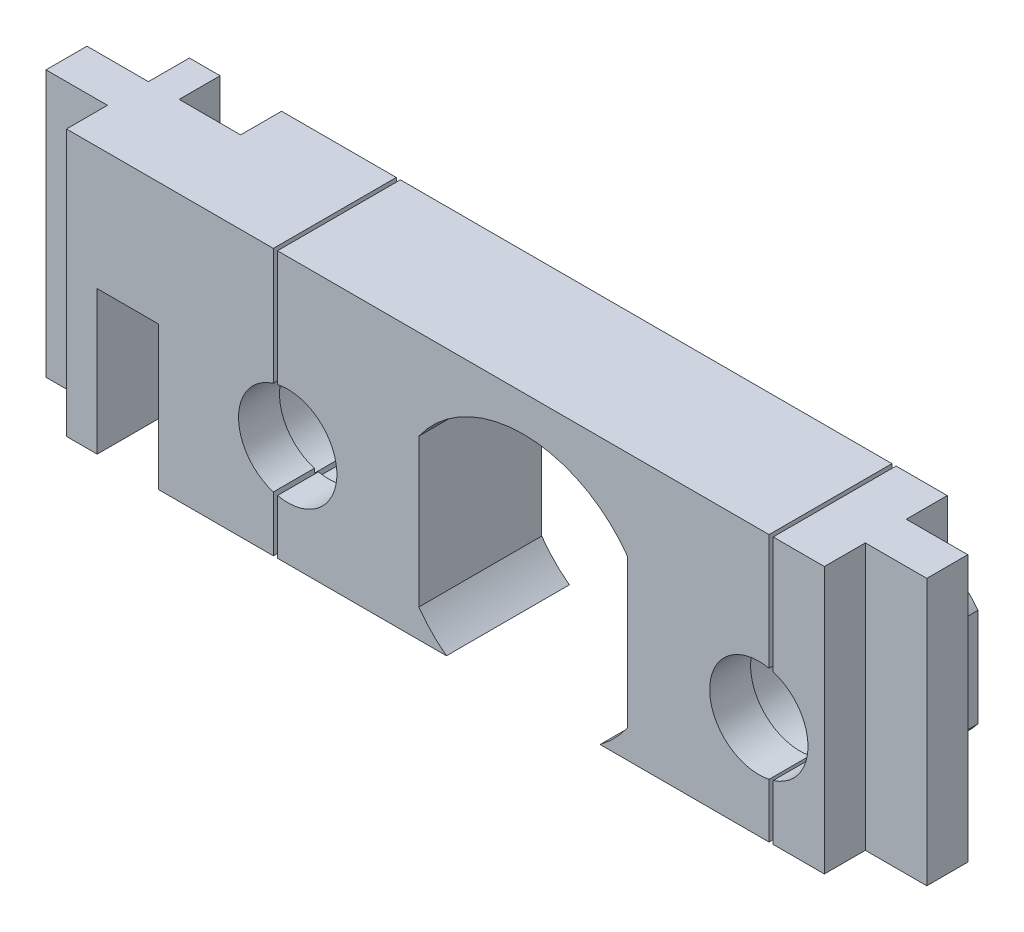
from build123d import *

# Parameters (mm, degrees)
SKETCH1_R            = 1
BOSS_EXTRUDE1_DEPTH  = 6
SKETCH2_R            = 2.6
CUT_EXTRUDE1_DEPTH   = 6
SKETCH3_W            = 7.6
SKETCH3_H            = 13
BOSS_EXTRUDE2_DEPTH  = 6
BOSS_EXTRUDE5_START  = -5
SKETCH6_W            = 3
SKETCH6_H            = 2
BOSS_EXTRUDE5_DEPTH  = 13
BOSS_EXTRUDE6_START  = -6
SKETCH10_R           = 4
SKETCH10_R_2         = 2.6
BOSS_EXTRUDE6_DEPTH  = 1.5
BOSS_EXTRUDE7_START  = -6
SKETCH12_R           = 2.6
SKETCH12_R_2         = 2.4
BOSS_EXTRUDE7_DEPTH  = 2
CUT_EXTRUDE2_DEPTH   = 7
SKETCH14_W           = 3
SKETCH14_H           = 6
CUT_EXTRUDE3_DEPTH   = 2
SKETCH15_W           = 0.2
SKETCH15_H           = 13
CUT_EXTRUDE5_DEPTH   = 7.5
SKETCH16_W           = 3
SKETCH16_H           = 3
CUT_EXTRUDE6_DEPTH   = 3
SKETCH17_W           = 2.8
SKETCH17_H           = 2.8
BOSS_EXTRUDE9_DEPTH  = 3
BOSS_EXTRUDE10_START = 24.4
SKETCH17_2_W         = 2.8
SKETCH17_2_H         = 2.8
BOSS_EXTRUDE10_DEPTH = 3


with BuildPart() as part:
    # Sketch1 → Boss-Extrude1 (new body)
    with BuildSketch(Plane.XY):
        with BuildLine():
            ThreePointArc((3.75, -5), (4.47902769, -4.358991965), (5.1, -3.61282438))
            Line((5.1, -3.61282438), (5.1, 3.61282438))
            ThreePointArc((5.1, 3.61282438), (0, 6.25), (-5.1, 3.61282438))
            Line((-5.1, 3.61282438), (-5.1, -3.61282438))
            ThreePointArc((-5.1, -3.61282438), (-4.47902769, -4.358991965), (-3.75, -5))
            Line((-3.75, -5), (-14.7, -5))
            Line((-14.7, -5), (-14.7, 8))
            Line((-14.7, 8), (14.7, 8))
            Line((14.7, 8), (14.7, -5))
            Line((14.7, -5), (3.75, -5))
        make_face()
        with Locations((11.5, 0)):
            Circle(SKETCH1_R, mode=Mode.SUBTRACT)
        with Locations((-11.5, 0)):
            Circle(SKETCH1_R, mode=Mode.SUBTRACT)
    extrude(amount=BOSS_EXTRUDE1_DEPTH)

    # Sketch2 → Cut-Extrude1 (cut)
    with BuildSketch(Plane.XY):
        with Locations((-11.5, 0)):
            Circle(SKETCH2_R)
        with Locations((11.5, 0)):
            Circle(SKETCH2_R)
    extrude(amount=CUT_EXTRUDE1_DEPTH, mode=Mode.SUBTRACT)

    # Sketch3 → Boss-Extrude2 (add)
    with BuildSketch(Plane.XY):
        with Locations((-18.5, 1.5)):
            Rectangle(SKETCH3_W, SKETCH3_H)
    extrude(amount=BOSS_EXTRUDE2_DEPTH)

    # Sketch6 → Boss-Extrude5 (add)
    with BuildSketch(Plane(origin=(0, 0, 0), x_dir=(1, 0, 0), z_dir=(0, 1, 0)).offset(BOSS_EXTRUDE5_START)):
        with Locations((-23.8, -3)):
            Rectangle(SKETCH6_W, SKETCH6_H)
        with Locations((16.2, -3)):
            Rectangle(SKETCH6_W, SKETCH6_H)
    extrude(amount=BOSS_EXTRUDE5_DEPTH)

    # Sketch10 → Boss-Extrude6 (add)
    with BuildSketch(Plane.XY.offset(6).offset(BOSS_EXTRUDE6_START)):
        with Locations((-11.5, 0)):
            Circle(SKETCH10_R)
        with Locations((-11.5, 0)):
            Circle(SKETCH10_R_2, mode=Mode.SUBTRACT)
        with BuildLine():
            Line((14.7, 2.4), (14.7, -2.4))
            ThreePointArc((14.7, -2.4), (7.5, 0), (14.7, 2.4))
        make_face()
        with Locations((11.5, 0)):
            Circle(SKETCH10_R_2, mode=Mode.SUBTRACT)
    extrude(amount=-BOSS_EXTRUDE6_DEPTH)

    # Sketch12 → Boss-Extrude7 (add)
    with BuildSketch(Plane(origin=(0, 0, 0), x_dir=(-1, 0, 0), z_dir=(0, 0, -1)).offset(BOSS_EXTRUDE7_START)):
        with Locations((11.5, 0)):
            Circle(SKETCH12_R)
        with Locations((11.5, 0)):
            Circle(SKETCH12_R_2, mode=Mode.SUBTRACT)
        with Locations((-11.5, 0)):
            Circle(SKETCH12_R)
        with Locations((-11.5, 0)):
            Circle(SKETCH12_R_2, mode=Mode.SUBTRACT)
    extrude(amount=BOSS_EXTRUDE7_DEPTH)

    # Sketch13 → Cut-Extrude2 (cut)
    with BuildSketch(Plane.XZ.offset(5)):
        Polygon((-22.3, 0), (-16.3, 0), (-16.3, 2), (-17.8, 2), (-17.8, 6), (-20.8, 6), (-20.8, 2), (-22.3, 2), align=None)
    extrude(amount=-CUT_EXTRUDE2_DEPTH, mode=Mode.SUBTRACT)

    # Sketch14 → Cut-Extrude3 (cut)
    with BuildSketch(Plane(origin=(0, 0, 0), x_dir=(-1, 0, 0), z_dir=(0, 0, -1))):
        with Locations((19.3, 5)):
            Rectangle(SKETCH14_W, SKETCH14_H)
    extrude(amount=-CUT_EXTRUDE3_DEPTH, mode=Mode.SUBTRACT)

    # Sketch15 → Cut-Extrude5 (cut, symmetric)
    with BuildSketch(Plane.XY):
        with Locations((-12.1, 1.5)):
            Rectangle(SKETCH15_W, SKETCH15_H)
        with Locations((12.1, 1.5)):
            Rectangle(SKETCH15_W, SKETCH15_H)
    extrude(amount=CUT_EXTRUDE5_DEPTH, both=True, mode=Mode.SUBTRACT)

    # Sketch16 → Cut-Extrude6 (cut)
    with BuildSketch(Plane(origin=(12, 0, 0), x_dir=(0, 0, -1), z_dir=(1, 0, 0))):
        with Locations((-3, 5.173669459)):
            Rectangle(SKETCH16_W, SKETCH16_H)
    cut_extrude6 = extrude(amount=-CUT_EXTRUDE6_DEPTH, mode=Mode.SUBTRACT)

    # Mirror1: Cut-Extrude6 across plane
    add(cut_extrude6.mirror(Plane(origin=(0, 0, 0), x_dir=(0, 0, 1), z_dir=(1, 0, 0))), mode=Mode.SUBTRACT)

    # Sketch17 → Boss-Extrude9 (add)
    with BuildSketch(Plane(origin=(-12.2, 0, 0), x_dir=(0, 0, -1), z_dir=(1, 0, 0))):
        with Locations((-3, 5.173669459)):
            Rectangle(SKETCH17_W, SKETCH17_H)
    extrude(amount=BOSS_EXTRUDE9_DEPTH)

    # Sketch17_2 → Boss-Extrude10 (add)
    with BuildSketch(Plane(origin=(-12.2, 0, 0), x_dir=(0, 0, -1), z_dir=(1, 0, 0)).offset(BOSS_EXTRUDE10_START)):
        with Locations((-3, 5.173669459)):
            Rectangle(SKETCH17_2_W, SKETCH17_2_H)
    extrude(amount=-BOSS_EXTRUDE10_DEPTH)


solid = part.part
